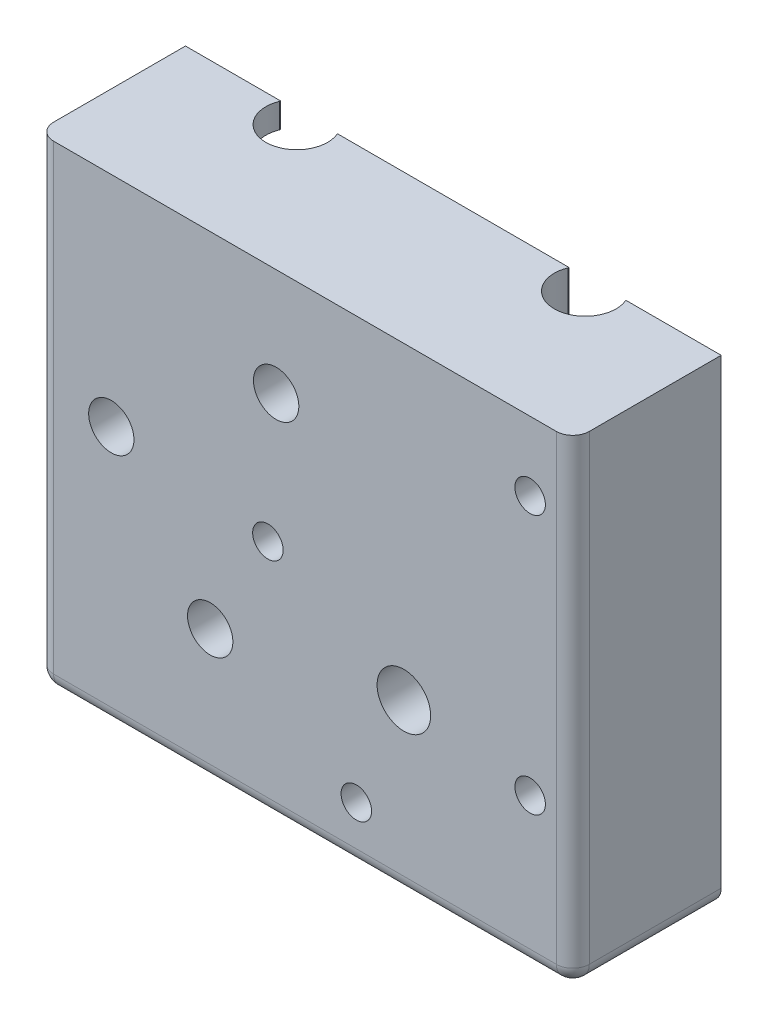
from build123d import *

# Parameters (mm, degrees)
SKETCH1_W             = 11.521135243
SKETCH1_H             = 3
BOSS_EXTRUDE1_DEPTH   = 10
SKETCH1_R             = 1.85
BOSS_EXTRUDE1_2_DEPTH = 10
BOSS_EXTRUDE1_3_DEPTH = 10
BOSS_EXTRUDE1_4_DEPTH = 10
BOSS_EXTRUDE1_5_DEPTH = 10
BOSS_EXTRUDE1_6_DEPTH = 10
SKETCH2_R             = 10
CUT_EXTRUDE1_DEPTH    = 11
SKETCH3_R             = 3.25
BOSS_EXTRUDE2_DEPTH   = 7.5
SKETCH4_R             = 1.85
SKETCH4_R_2           = 3.25
BOSS_EXTRUDE3_DEPTH   = 2
SKETCH5_R             = 3.25
SKETCH5_R_2           = 1.85
BOSS_EXTRUDE4_DEPTH   = 6
FILLET1_R             = 2
SKETCH6_W             = 9
SKETCH6_H             = 20
CUT_EXTRUDE2_DEPTH    = 12
SKETCH7_W             = 2.997729514
SKETCH7_H             = 29.62259405
CUT_EXTRUDE3_DEPTH    = 9.5
SKETCH8_R             = 2.75
CUT_EXTRUDE4_DEPTH    = 6
SKETCH9_R             = 2.75
CUT_EXTRUDE5_DEPTH    = 16.5
SKETCH10_R            = 1.85
CUT_EXTRUDE6_DEPTH    = 25
SKETCH11_R            = 1.85
BOSS_EXTRUDE5_DEPTH   = 18
SKETCH12_R            = 3.75
CUT_EXTRUDE7_DEPTH    = 59
SKETCH13_R            = 7.5
CUT_EXTRUDE8_DEPTH    = 10


with BuildPart() as part:
    # Sketch1 → Boss-Extrude1 (new body)
    with BuildSketch(Plane.XY):
        with Locations((-38.739432378, 36)):
            Rectangle(SKETCH1_W, SKETCH1_H)
    extrude(amount=BOSS_EXTRUDE1_DEPTH)



with BuildPart() as body_2:
    # Sketch1 → Boss-Extrude1 2 (new body)
    with BuildSketch(Plane.XY):
        with BuildLine():
            Line((-26.021135243, 30.5), (-26.021135243, 5.429840229))
            ThreePointArc((-26.021135243, 5.429840229), (-19.754753142, 5.025033011), (-14.965174817, 0.964078321))
            Line((-14.965174817, 0.964078321), (-7.099804938, -1.468083732))
            ThreePointArc((-7.099804938, -1.468083732), (-5.680207241, 4.505301955), (-0.18689792, 7.247590577))
            Line((-0.18689792, 7.247590577), (-7.105071526, 19.066292618))
            ThreePointArc((-7.105071526, 19.066292618), (-9.465636422, 16.525888375), (-12.551889075, 14.944444444))
            ThreePointArc((-12.551889075, 14.944444444), (-15.5, 12.5), (-18.448110925, 14.944444444))
            ThreePointArc((-18.448110925, 14.944444444), (-25.010999441, 21.411166946), (-23.5, 30.5))
            Line((-23.5, 30.5), (-26.021135243, 30.5))
        make_face()
        with Locations((-10.762282528, 8.436432064)):
            Circle(SKETCH1_R, mode=Mode.SUBTRACT)
    extrude(amount=BOSS_EXTRUDE1_2_DEPTH)


with BuildPart() as body_3:
    # Sketch1 → Boss-Extrude1 3 (new body)
    with BuildSketch(Plane.XY):
        with BuildLine():
            Line((-26.021135243, 37.5), (-26.021135243, 34.5))
            Line((-26.021135243, 34.5), (-15.5, 34.5))
            ThreePointArc((-15.5, 34.5), (-7.78005297, 30.856289629), (-5.685956151, 22.58048357))
            Line((-5.685956151, 22.58048357), (2.021135243, 9.414029247))
            Line((2.021135243, 9.414029247), (2.021135243, 37.5))
            Line((2.021135243, 37.5), (-26.021135243, 37.5))
        make_face()
    extrude(amount=BOSS_EXTRUDE1_3_DEPTH)


with BuildPart() as body_4:
    # Sketch1 → Boss-Extrude1 4 (new body)
    with BuildSketch(Plane.XY):
        with BuildLine():
            Line((8.978864757, 37.5), (8.978864757, -20.5))
            Line((8.978864757, -20.5), (18.5, -20.5))
            ThreePointArc((18.5, -20.5), (19.914213562, -19.914213562), (20.5, -18.5))
            Line((20.5, -18.5), (20.5, 37.5))
            Line((20.5, 37.5), (8.978864757, 37.5))
        make_face()
        with Locations((15.322226869, 29.126922543)):
            Circle(SKETCH1_R, mode=Mode.SUBTRACT)
        with Locations((15.322226869, -2.351605773)):
            Circle(SKETCH1_R, mode=Mode.SUBTRACT)
    extrude(amount=BOSS_EXTRUDE1_4_DEPTH)


with BuildPart() as body_5:
    # Sketch1 → Boss-Extrude1 5 (new body)
    with BuildSketch(Plane.XY):
        with BuildLine():
            Line((-26.021135243, -14.247136421), (-26.021135243, -20.5))
            Line((-26.021135243, -20.5), (2.021135243, -20.5))
            Line((2.021135243, -20.5), (2.021135243, -6.962579431))
            ThreePointArc((2.021135243, -6.962579431), (-1.710141081, -7.045418191), (-4.98822277, -5.261191271))
            Line((-4.98822277, -5.261191271), (-13.638901361, -2.586192825))
            ThreePointArc((-13.638901361, -2.586192825), (-15.864247386, -10.70432482), (-23.5, -14.247136421))
            Line((-23.5, -14.247136421), (-26.021135243, -14.247136421))
        make_face()
        with Locations((-5.770802335, -13.622690081)):
            Circle(SKETCH1_R, mode=Mode.SUBTRACT)
    extrude(amount=BOSS_EXTRUDE1_5_DEPTH)


with BuildPart() as body_6:
    # Sketch1 → Boss-Extrude1 6 (new body)
    with BuildSketch(Plane.XY):
        with BuildLine():
            Line((-32.978864757, 12.098351987), (-32.978864757, 30.5))
            Line((-32.978864757, 30.5), (-44.5, 30.5))
            Line((-44.5, 30.5), (-44.5, -18.5))
            ThreePointArc((-44.5, -18.5), (-43.914213562, -19.914213562), (-42.5, -20.5))
            Line((-42.5, -20.5), (-32.978864757, -20.5))
            Line((-32.978864757, -20.5), (-32.978864757, -7.433219111))
            ThreePointArc((-32.978864757, -7.433219111), (-33.5, -4.247136421), (-32.978864757, -1.06105373))
            Line((-32.978864757, -1.06105373), (-32.978864757, 9.901648013))
            ThreePointArc((-32.978864757, 9.901648013), (-38.25, 11), (-32.978864757, 12.098351987))
        make_face()
    extrude(amount=BOSS_EXTRUDE1_6_DEPTH)


with BuildPart() as cut_extrude1_tool:
    # Sketch2 → Cut-Extrude1 (new body, through all)
    with BuildSketch(Plane.XY.offset(10)):
        with Locations((-35.5, 11)):
            Circle(SKETCH2_R)
    extrude(amount=-CUT_EXTRUDE1_DEPTH)


with BuildPart() as body_2_1:
    add(body_2.part)

    # Cut-Extrude1: cut by cut_extrude1_tool
    add(cut_extrude1_tool.part, mode=Mode.SUBTRACT)


with BuildPart() as body_6_1:
    add(body_6.part)

    # Cut-Extrude1: cut by cut_extrude1_tool
    add(cut_extrude1_tool.part, mode=Mode.SUBTRACT)


with BuildPart() as part_1:
    add(part.part)

    add(body_2_1.part)  # Boss-Extrude2 merges body 2

    add(body_3.part)  # Boss-Extrude2 merges body 3

    add(body_4.part)  # Boss-Extrude2 merges body 4

    add(body_5.part)  # Boss-Extrude2 merges body 5

    add(body_6_1.part)  # Boss-Extrude2 merges body 6
    # Sketch3 → Boss-Extrude2 (add)
    with BuildSketch(Plane.XY.offset(10)):
        with BuildLine():
            Line((-32.978864757, 20.67697665), (-32.978864757, 30.5))
            Line((-32.978864757, 30.5), (-44.5, 30.5))
            Line((-44.5, 30.5), (-44.5, 34.5))
            Line((-44.5, 34.5), (-32.978864757, 34.5))
            Line((-32.978864757, 34.5), (-32.978864757, 37.5))
            Line((-32.978864757, 37.5), (-26.021135243, 37.5))
            Line((-26.021135243, 37.5), (-26.021135243, 34.5))
            Line((-26.021135243, 34.5), (-15.5, 34.5))
            ThreePointArc((-15.5, 34.5), (-7.78005297, 30.856289629), (-5.685956151, 22.58048357))
            Line((-5.685956151, 22.58048357), (2.021135243, 9.414029247))
            Line((2.021135243, 9.414029247), (2.021135243, 37.5))
            Line((2.021135243, 37.5), (8.978864757, 37.5))
            Line((8.978864757, 37.5), (8.978864757, -20.5))
            Line((8.978864757, -20.5), (2.021135243, -20.5))
            Line((2.021135243, -20.5), (2.021135243, -6.962579431))
            ThreePointArc((2.021135243, -6.962579431), (-1.710141081, -7.045418191), (-4.98822277, -5.261191271))
            Line((-4.98822277, -5.261191271), (-13.638901361, -2.586192825))
            ThreePointArc((-13.638901361, -2.586192825), (-15.864247386, -10.70432482), (-23.5, -14.247136421))
            Line((-23.5, -14.247136421), (-26.021135243, -14.247136421))
            Line((-26.021135243, -14.247136421), (-26.021135243, -20.5))
            Line((-26.021135243, -20.5), (-32.978864757, -20.5))
            Line((-32.978864757, -20.5), (-32.978864757, -7.433219111))
            ThreePointArc((-32.978864757, -7.433219111), (-33.5, -4.247136421), (-32.978864757, -1.06105373))
            Line((-32.978864757, -1.06105373), (-32.978864757, 1.32302335))
            ThreePointArc((-32.978864757, 1.32302335), (-28.67849532, 3.687881709), (-26.021135243, 7.813917309))
            Line((-26.021135243, 7.813917309), (-26.021135243, 5.429840229))
            ThreePointArc((-26.021135243, 5.429840229), (-19.754753142, 5.025033011), (-14.965174817, 0.964078321))
            Line((-14.965174817, 0.964078321), (-7.099804938, -1.468083732))
            ThreePointArc((-7.099804938, -1.468083732), (-5.680207241, 4.505301955), (-0.18689792, 7.247590577))
            Line((-0.18689792, 7.247590577), (-7.105071526, 19.066292618))
            ThreePointArc((-7.105071526, 19.066292618), (-9.465636422, 16.525888375), (-12.551889075, 14.944444444))
            ThreePointArc((-12.551889075, 14.944444444), (-15.5, 12.5), (-18.448110925, 14.944444444))
            ThreePointArc((-18.448110925, 14.944444444), (-25.010999441, 21.411166946), (-23.5, 30.5))
            Line((-23.5, 30.5), (-26.021135243, 30.5))
            Line((-26.021135243, 30.5), (-26.021135243, 14.186082691))
            ThreePointArc((-26.021135243, 14.186082691), (-28.67849532, 18.312118291), (-32.978864757, 20.67697665))
        make_face()
        Circle(SKETCH3_R, mode=Mode.SUBTRACT)
    extrude(amount=-BOSS_EXTRUDE2_DEPTH)

    # Sketch4 → Boss-Extrude3 (add)
    with BuildSketch(Plane.XY.offset(10)):
        with BuildLine():
            Line((-44.5, 6.641101056), (-44.5, -18.5))
            ThreePointArc((-44.5, -18.5), (-43.914213562, -19.914213562), (-42.5, -20.5))
            Line((-42.5, -20.5), (18.5, -20.5))
            ThreePointArc((18.5, -20.5), (19.914213562, -19.914213562), (20.5, -18.5))
            Line((20.5, -18.5), (20.5, 37.5))
            Line((20.5, 37.5), (-44.5, 37.5))
            Line((-44.5, 37.5), (-44.5, 15.358898944))
            ThreePointArc((-44.5, 15.358898944), (-25.5, 11), (-44.5, 6.641101056))
        make_face()
        with Locations((-10.762282528, 8.436432064)):
            Circle(SKETCH4_R, mode=Mode.SUBTRACT)
        Circle(SKETCH4_R_2, mode=Mode.SUBTRACT)
        with Locations((-5.770802335, -13.622690081)):
            Circle(SKETCH4_R, mode=Mode.SUBTRACT)
        with Locations((15.322226869, -2.351605773)):
            Circle(SKETCH4_R, mode=Mode.SUBTRACT)
        with Locations((15.322226869, 29.126922543)):
            Circle(SKETCH4_R, mode=Mode.SUBTRACT)
    extrude(amount=BOSS_EXTRUDE3_DEPTH)

    # Sketch5 → Boss-Extrude4 (add)
    with BuildSketch(Plane.XY.offset(12)):
        with BuildLine():
            Line((-44.5, 37.5), (20.5, 37.5))
            Line((20.5, 37.5), (20.5, -18.5))
            ThreePointArc((20.5, -18.5), (19.914213562, -19.914213562), (18.5, -20.5))
            Line((18.5, -20.5), (-42.5, -20.5))
            ThreePointArc((-42.5, -20.5), (-43.914213562, -19.914213562), (-44.5, -18.5))
            Line((-44.5, -18.5), (-44.5, 37.5))
        make_face()
        Circle(SKETCH5_R, mode=Mode.SUBTRACT)
        with Locations((-10.762282528, 8.436432064)):
            Circle(SKETCH5_R_2, mode=Mode.SUBTRACT)
        with Locations((15.322226869, 29.126922543)):
            Circle(SKETCH5_R_2, mode=Mode.SUBTRACT)
        with Locations((15.322226869, -2.351605773)):
            Circle(SKETCH5_R_2, mode=Mode.SUBTRACT)
        with Locations((-5.770802335, -13.622690081)):
            Circle(SKETCH5_R_2, mode=Mode.SUBTRACT)
    extrude(amount=BOSS_EXTRUDE4_DEPTH)

    # Fillet1
    fillet1_edges = [part_1.edges().sort_by_distance(p)[0] for p in [
        (-44.5, 9.5, 18),
        (-43.914213562, -19.914213562, 18),
        (-12, -20.5, 18),
        (19.914213562, -19.914213562, 18),
        (20.5, 9.5, 18),
    ]]
    fillet(fillet1_edges, radius=FILLET1_R)

    # Sketch6 → Cut-Extrude2 (cut)
    with BuildSketch(Plane(origin=(0, 0, 0), x_dir=(-1, 0, 0), z_dir=(0, 0, -1))):
        with Locations((40, 11)):
            Rectangle(SKETCH6_W, SKETCH6_H)
    extrude(amount=-CUT_EXTRUDE2_DEPTH, mode=Mode.SUBTRACT)

    # Sketch7 → Cut-Extrude3 (cut)
    with BuildSketch(Plane(origin=(0, 0, 2.5), x_dir=(-1, 0, 0), z_dir=(0, 0, -1))):
        with Locations((29.5, -5.688702975)):
            Rectangle(SKETCH7_W, SKETCH7_H)
    extrude(amount=-CUT_EXTRUDE3_DEPTH, mode=Mode.SUBTRACT)

    # Sketch8 → Cut-Extrude4 (cut)
    with BuildSketch(Plane(origin=(0, 0, 12), x_dir=(-1, 0, 0), z_dir=(0, 0, -1))):
        with Locations((35.5, 11)):
            Circle(SKETCH8_R)
    extrude(amount=-CUT_EXTRUDE4_DEPTH, mode=Mode.SUBTRACT)

    # Sketch9 → Cut-Extrude5 (cut, through all)
    with BuildSketch(Plane(origin=(0, 0, 2.5), x_dir=(-1, 0, 0), z_dir=(0, 0, -1))):
        with Locations((15.5, 24.5)):
            Circle(SKETCH9_R)
        with Locations((23.5, -4.247136421)):
            Circle(SKETCH9_R)
    extrude(amount=-CUT_EXTRUDE5_DEPTH, mode=Mode.SUBTRACT)

    # Sketch10 → Cut-Extrude6 (cut)
    with BuildSketch(Plane.XY.offset(18)):
        with Locations((-16.5, 8.436432064)):
            Circle(SKETCH10_R)
    extrude(amount=-CUT_EXTRUDE6_DEPTH, mode=Mode.SUBTRACT)

    # Sketch11 → Boss-Extrude5 (add, through all)
    with BuildSketch(Plane.XY.offset(18)):
        with Locations((-10.762282528, 8.436432064)):
            Circle(SKETCH11_R)
    extrude(amount=-BOSS_EXTRUDE5_DEPTH)

    # Sketch12 → Cut-Extrude7 (cut, through all)
    with BuildSketch(Plane.XZ.offset(20.5)):
        with Locations((-29.498864757, 1.5)):
            Circle(SKETCH12_R)
        with Locations((5.498864757, 1.5)):
            Circle(SKETCH12_R)
    extrude(amount=-CUT_EXTRUDE7_DEPTH, mode=Mode.SUBTRACT)

    # Sketch13 → Cut-Extrude8 (cut)
    with BuildSketch(Plane(origin=(0, 0, 2.5), x_dir=(-1, 0, 0), z_dir=(0, 0, -1))):
        Circle(SKETCH13_R)
    extrude(amount=-CUT_EXTRUDE8_DEPTH, mode=Mode.SUBTRACT)


solid = part_1.part
